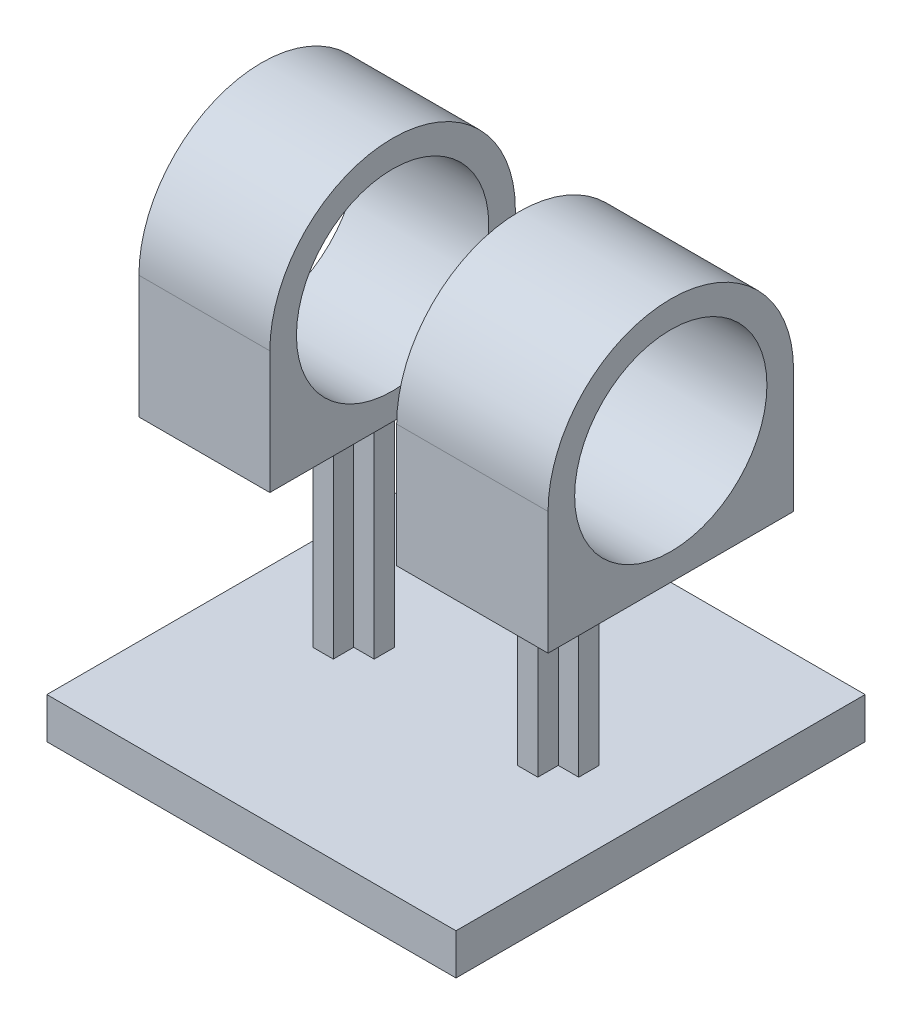
from build123d import *

# Parameters (mm, degrees)
ESQUISSE1_W             = 100
ESQUISSE1_H             = 100
BOSS_EXTRU_1_DEPTH      = 10
BOSS_EXTRU_2_DEPTH      = 50
ESQUISSE3_R             = 23.5
BOSS_EXTRU_3_DEPTH      = 20
BOSS_EXTRU_3_DEPTH_BACK = 80
ESQUISSE4_W             = 31
ESQUISSE4_H             = 60
ENL_V_MAT_EXTRU_1_DEPTH = 60


with BuildPart() as part:
    # Esquisse1 → Boss.-Extru.1 (new body)
    with BuildSketch(Plane(origin=(0, 0, 0), x_dir=(1, 0, 0), z_dir=(0, 1, 0))):
        Rectangle(ESQUISSE1_W, ESQUISSE1_H)
    extrude(amount=BOSS_EXTRU_1_DEPTH)

    # Esquisse2 → Boss.-Extru.2 (add)
    with BuildSketch(Plane(origin=(0, 10, 0), x_dir=(1, 0, 0), z_dir=(0, 1, 0))):
        Polygon((-27.5, 2.5), (-27.5, 7.5), (-22.5, 7.5), (-22.5, 2.5), (-17.5, 2.5), (-17.5, -2.5), (-22.5, -2.5), (-22.5, -7.5), (-27.5, -7.5), (-27.5, -2.5), (-32.5, -2.5), (-32.5, 2.5), align=None)
        Polygon((27.5, -7.5), (27.5, -2.5), (32.5, -2.5), (32.5, 2.5), (27.5, 2.5), (27.5, 7.5), (22.5, 7.5), (22.5, 2.5), (17.5, 2.5), (17.5, -2.5), (22.5, -2.5), (22.5, -7.5), align=None)
    extrude(amount=BOSS_EXTRU_2_DEPTH)


with BuildPart() as body_2:
    # Esquisse3 → Boss.-Extru.3 (new body, two sides)
    with BuildSketch(Plane(origin=(32.5, 0, 0), x_dir=(0, 0, -1), z_dir=(1, 0, 0))) as boss_extru_3_sk:
        with BuildLine():
            Line((0, 60), (-30, 60))
            Line((-30, 60), (-30, 90))
            ThreePointArc((-30, 90), (0, 120), (30, 90))
            Line((30, 90), (30, 60))
            Line((30, 60), (0, 60))
        make_face()
        with Locations((0, 90)):
            Circle(ESQUISSE3_R, mode=Mode.SUBTRACT)
    extrude(amount=BOSS_EXTRU_3_DEPTH)
    extrude(boss_extru_3_sk.sketch, amount=-BOSS_EXTRU_3_DEPTH_BACK)

    # Esquisse4 → Enlèv. mat.-Extru.1 (cut)
    with BuildSketch(Plane(origin=(0, 0, -30), x_dir=(-1, 0, 0), z_dir=(0, 0, -1))):
        with Locations((0, 90)):
            Rectangle(ESQUISSE4_W, ESQUISSE4_H)
    extrude(amount=-ENL_V_MAT_EXTRU_1_DEPTH, mode=Mode.SUBTRACT)


solid = Compound([part.part, body_2.part])
